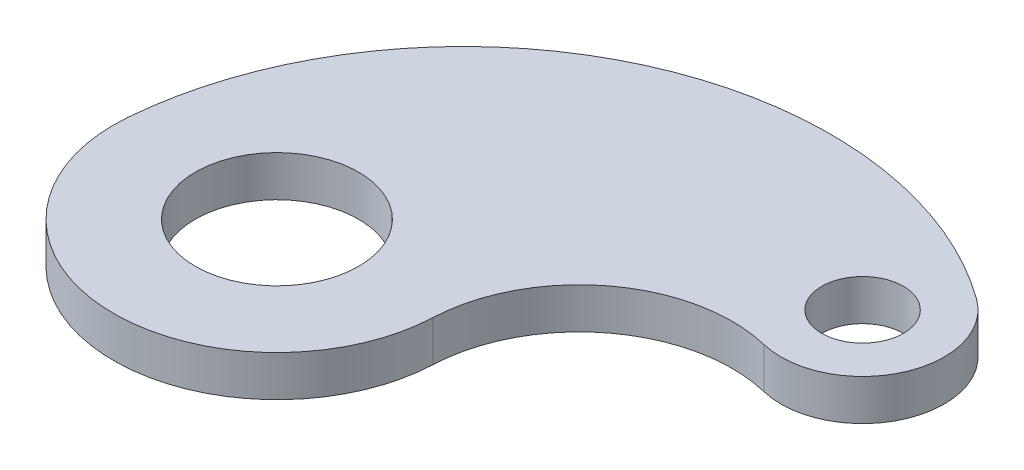
from build123d import *

# Parameters (mm, degrees)
CROQUIS4_R              = 40
CROQUIS4_R_2            = 20
SALIENTE_EXTRUIR2_DEPTH = 20


with BuildPart() as part:
    # Croquis4 → Saliente-Extruir2 (new body)
    with BuildSketch(Plane(origin=(0, 0, 0), x_dir=(1, 0, 0), z_dir=(0, 1, 0))):
        with BuildLine():
            ThreePointArc((-79.722697138, 6.655190531), (-5.078826092, -79.838621766), (79.923379849, -3.500479035))
            ThreePointArc((79.923379849, -3.500479035), (109.764419077, 53.152375878), (172.469235199, 66.119242389))
            ThreePointArc((172.469235199, 66.119242389), (218.184271838, 88.238889892), (205.354467187, 137.376853761))
            ThreePointArc((205.354467187, 137.376853761), (24.626451497, 155.299352148), (-79.722697138, 6.655190531))
        make_face()
        Circle(CROQUIS4_R, mode=Mode.SUBTRACT)
        with Locations((181.865334795, 105)):
            Circle(CROQUIS4_R_2, mode=Mode.SUBTRACT)
    extrude(amount=SALIENTE_EXTRUIR2_DEPTH)


solid = part.part
